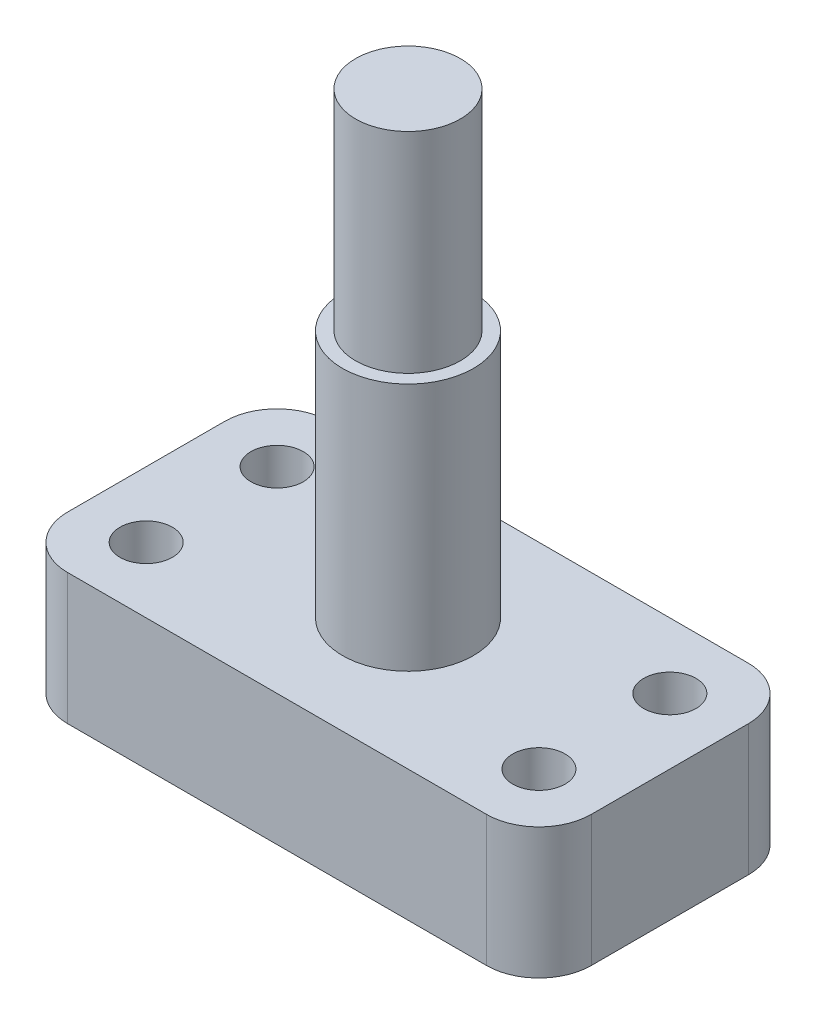
from build123d import *

# Parameters (mm, degrees)
SKETCH1_R           = 2
BOSS_EXTRUDE1_DEPTH = 10
SKETCH2_R           = 5
BOSS_EXTRUDE2_DEPTH = 19
SKETCH3_R           = 4
BOSS_EXTRUDE3_DEPTH = 16


with BuildPart() as part:
    # Sketch1 → Boss-Extrude1 (new body)
    with BuildSketch(Plane(origin=(0, 0, 0), x_dir=(1, 0, 0), z_dir=(0, 1, 0))):
        with BuildLine():
            Line((4, 0), (36, 0))
            ThreePointArc((36, 0), (38.828427125, 1.171572875), (40, 4))
            Line((40, 4), (40, 16))
            ThreePointArc((40, 16), (38.828427125, 18.828427125), (36, 20))
            Line((36, 20), (4, 20))
            ThreePointArc((4, 20), (1.171572875, 18.828427125), (0, 16))
            Line((0, 16), (0, 4))
            ThreePointArc((0, 4), (1.171572875, 1.171572875), (4, 0))
        make_face()
        with Locations((5, 15)):
            Circle(SKETCH1_R, mode=Mode.SUBTRACT)
        with Locations((5, 5)):
            Circle(SKETCH1_R, mode=Mode.SUBTRACT)
        with Locations((35, 5)):
            Circle(SKETCH1_R, mode=Mode.SUBTRACT)
        with Locations((35, 15)):
            Circle(SKETCH1_R, mode=Mode.SUBTRACT)
    extrude(amount=BOSS_EXTRUDE1_DEPTH)

    # Sketch2 → Boss-Extrude2 (add)
    with BuildSketch(Plane(origin=(0, 10, 0), x_dir=(1, 0, 0), z_dir=(0, 1, 0))):
        with Locations((20, 10)):
            Circle(SKETCH2_R)
    extrude(amount=BOSS_EXTRUDE2_DEPTH)

    # Sketch3 → Boss-Extrude3 (add)
    with BuildSketch(Plane(origin=(0, 29, 0), x_dir=(1, 0, 0), z_dir=(0, 1, 0))):
        with Locations((20, 10)):
            Circle(SKETCH3_R)
    extrude(amount=BOSS_EXTRUDE3_DEPTH)


solid = part.part
